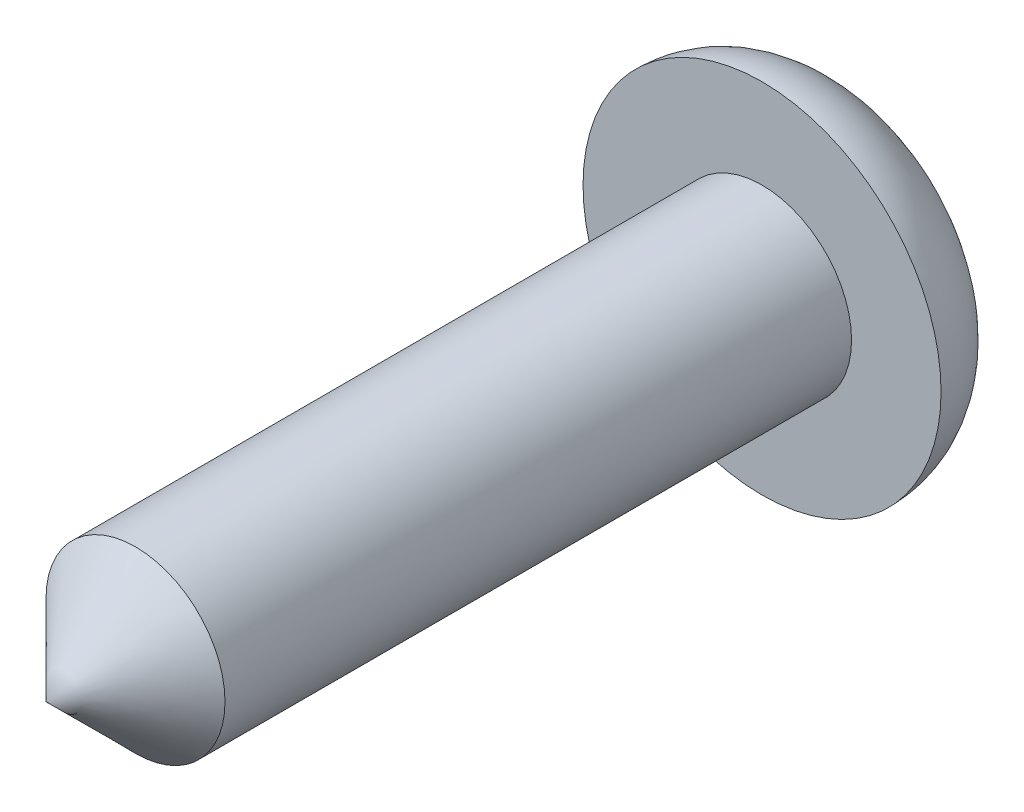
from build123d import *


with BuildPart() as part:
    # Sketch1 → Revolve1 (revolve)
    with BuildSketch(Plane(origin=(0, 0, 0), x_dir=(1, 0, 0), z_dir=(0, 1, 0))):
        with BuildLine():
            Line((-1, -1), (-1, -8))
            Line((-1, -8), (0, -9))
            Line((0, -9), (0, 0))
            Line((0, 0), (-1, 0))
            ThreePointArc((-1, 0), (-1.707106781, -0.292893219), (-2, -1))
            Line((-2, -1), (-1, -1))
        make_face()
    revolve(axis=Axis((0, 0, 9), (0, 0, -1)))


solid = part.part
